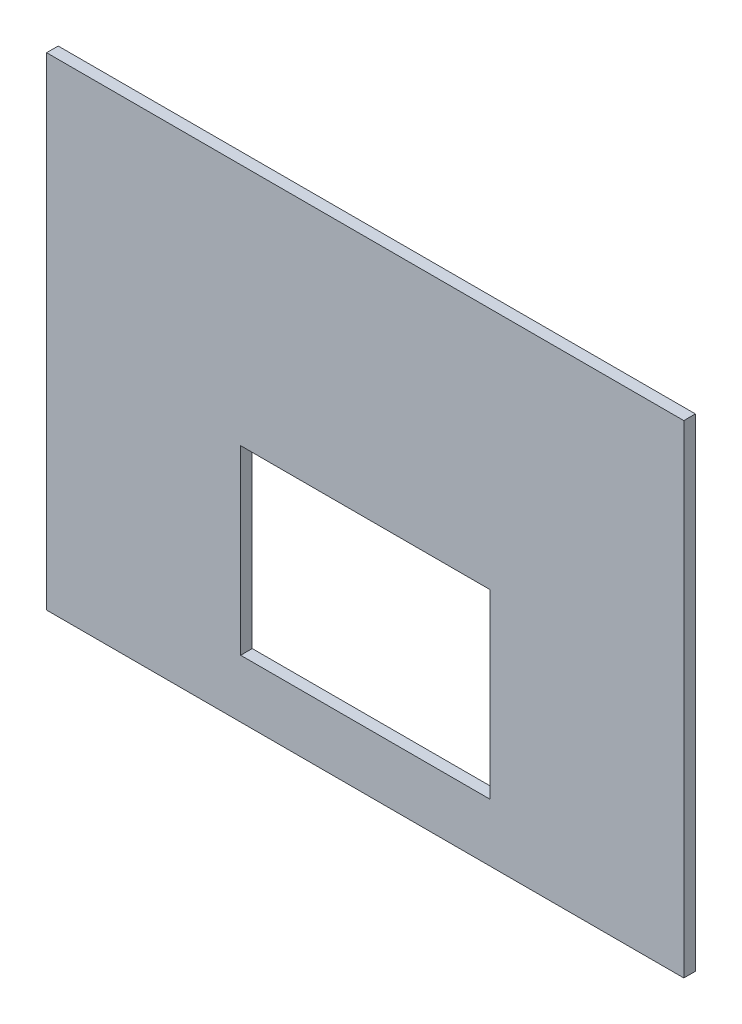
from build123d import *

# Parameters (mm, degrees)
ESQUISSE1_W        = 330
ESQUISSE1_H        = 250
ESQUISSE1_W_2      = 129
ESQUISSE1_H_2      = 94
BOSS_EXTRU_1_DEPTH = 6


with BuildPart() as part:
    # Esquisse1 → Boss.-Extru.1 (new body)
    with BuildSketch(Plane.XY):
        with Locations((35.763691323, 72.899931008)):
            Rectangle(ESQUISSE1_W, ESQUISSE1_H)
        with Locations((35.763691323, 24.899931008)):
            Rectangle(ESQUISSE1_W_2, ESQUISSE1_H_2, mode=Mode.SUBTRACT)
    extrude(amount=BOSS_EXTRU_1_DEPTH)


solid = part.part
